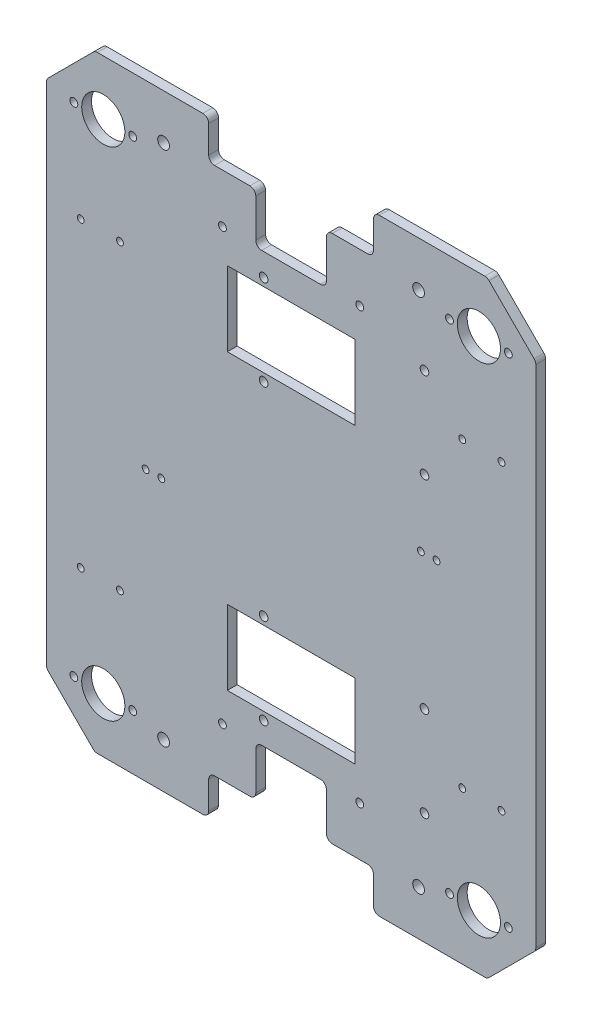
from build123d import *

# Parameters (mm, degrees)
BASE_DEPTH                            = 5
ESQUISSE3_R                           = 2
ESQUISSE3_W                           = 65
ESQUISSE3_H                           = 30
PER_AGE_ROUES_ENCODEUSES_DEPTH        = 6
CONG_1_R                              = 3
PER_AGE_BILLES_PORTEUSES_REACH        = 7
ESQUISSE6_R                           = 2
ESQUISSE6_R_2                         = 11
PER_AGE_PROFIL_S_REACH                = 7
ESQUISSE8_R                           = 3
ESQUISSE15_R                          = 2.2
PER_AGE_BLOC_MOTEUR_DEPTH             = 5
ESQUISSE16_W                          = 65
ESQUISSE16_H                          = 38
ENL_V_MAT_EXTRU_1_DEPTH               = 6
ESQUISSE19_R                          = 1.75
PER_AGE_ACTIONNEUR_MAIN_DE_DIEU_DEPTH = 6


with BuildPart() as part:
    # Esquisse1 → Base (new body)
    with BuildSketch(Plane.XY):
        Polygon((0, 0), (-200, 0), (-224.748737342, 24.748737342), (-224.748737342, 284.748737342), (-200, 309.497474683), (0, 309.497474683), (24.748737342, 284.748737342), (24.748737342, 24.748737342), align=None)
    extrude(amount=BASE_DEPTH)

    # Esquisse3 → Perçage roues encodeuses (cut, through all)
    with BuildSketch(Plane(origin=(0, 0, 0), x_dir=(-1, 0, 0), z_dir=(0, 0, -1))):
        with Locations((65, 45)):
            Circle(ESQUISSE3_R)
        with Locations((135, 45)):
            Circle(ESQUISSE3_R)
        with Locations((135, 264.497474683)):
            Circle(ESQUISSE3_R)
        with Locations((65, 264.497474683)):
            Circle(ESQUISSE3_R)
        Polygon((142, 0), (142, 20), (118, 20), (118, 45.5), (82, 45.5), (82, 20), (58, 20), (58, 0), align=None)
        Polygon((58, 309.497474683), (142, 309.497474683), (142, 289.497474683), (118, 289.497474683), (118, 263.997474683), (82, 263.997474683), (82, 289.497474683), (58, 289.497474683), align=None)
        with Locations((100, 229.497474683)):
            Rectangle(ESQUISSE3_W, ESQUISSE3_H)
        with Locations((100, 80)):
            Rectangle(ESQUISSE3_W, ESQUISSE3_H)
    extrude(amount=-PER_AGE_ROUES_ENCODEUSES_DEPTH, mode=Mode.SUBTRACT)

    # Congé1
    cong_1_edges = [part.edges().sort_by_distance(p)[0] for p in [
        (0, 0, 2.5),
        (-200, 0, 2.5),
        (-224.748737342, 24.748737342, 2.5),
        (-224.748737342, 284.748737342, 2.5),
        (-200, 309.497474683, 2.5),
        (0, 309.497474683, 2.5),
        (24.748737342, 284.748737342, 2.5),
        (24.748737342, 24.748737342, 2.5),
        (-58, 289.497474683, 2.5),
        (-58, 309.497474683, 2.5),
        (-142, 309.497474683, 2.5),
        (-142, 289.497474683, 2.5),
        (-118, 289.497474683, 2.5),
        (-118, 263.997474683, 2.5),
        (-82, 263.997474683, 2.5),
        (-82, 289.497474683, 2.5),
        (-142, 0, 2.5),
        (-58, 0, 2.5),
        (-58, 20, 2.5),
        (-82, 20, 2.5),
        (-82, 45.5, 2.5),
        (-118, 45.5, 2.5),
        (-118, 20, 2.5),
        (-142, 20, 2.5),
    ]]
    fillet(cong_1_edges, radius=CONG_1_R)

    # Esquisse6 → Perçage billes porteuses (cut, up to next)
    with BuildSketch(Plane.XY.offset(5), mode=Mode.PRIVATE) as per_age_billes_porteuses_sk1:
        with Locations((-180.748737342, 28)):
            Circle(ESQUISSE6_R)
    per_age_billes_porteuses_tool1 = extrude(per_age_billes_porteuses_sk1.sketch, amount=-PER_AGE_BILLES_PORTEUSES_REACH, mode=Mode.PRIVATE) & part.part
    add(per_age_billes_porteuses_tool1.solids().sort_by_distance((-180.748737, 28, 5))[0], mode=Mode.SUBTRACT)
    # Esquisse6 → Perçage billes porteuses (cut, up to next)
    with BuildSketch(Plane.XY.offset(5), mode=Mode.PRIVATE) as per_age_billes_porteuses_sk2:
        with Locations((-210.748737342, 28)):
            Circle(ESQUISSE6_R)
    per_age_billes_porteuses_tool2 = extrude(per_age_billes_porteuses_sk2.sketch, amount=-PER_AGE_BILLES_PORTEUSES_REACH, mode=Mode.PRIVATE) & part.part
    add(per_age_billes_porteuses_tool2.solids().sort_by_distance((-210.748737, 28, 5))[0], mode=Mode.SUBTRACT)
    # Esquisse6 → Perçage billes porteuses (cut, up to next)
    with BuildSketch(Plane.XY.offset(5), mode=Mode.PRIVATE) as per_age_billes_porteuses_sk3:
        with Locations((-195.748737342, 28)):
            Circle(ESQUISSE6_R_2)
    per_age_billes_porteuses_tool3 = extrude(per_age_billes_porteuses_sk3.sketch, amount=-PER_AGE_BILLES_PORTEUSES_REACH, mode=Mode.PRIVATE) & part.part
    add(per_age_billes_porteuses_tool3.solids().sort_by_distance((-195.748737, 28, 5))[0], mode=Mode.SUBTRACT)
    # Esquisse6 → Perçage billes porteuses (cut, up to next)
    with BuildSketch(Plane.XY.offset(5), mode=Mode.PRIVATE) as per_age_billes_porteuses_sk4:
        with Locations((-19.251262658, 28)):
            Circle(ESQUISSE6_R)
    per_age_billes_porteuses_tool4 = extrude(per_age_billes_porteuses_sk4.sketch, amount=-PER_AGE_BILLES_PORTEUSES_REACH, mode=Mode.PRIVATE) & part.part
    add(per_age_billes_porteuses_tool4.solids().sort_by_distance((-19.251263, 28, 5))[0], mode=Mode.SUBTRACT)
    # Esquisse6 → Perçage billes porteuses (cut, up to next)
    with BuildSketch(Plane.XY.offset(5), mode=Mode.PRIVATE) as per_age_billes_porteuses_sk5:
        with Locations((10.748737342, 28)):
            Circle(ESQUISSE6_R)
    per_age_billes_porteuses_tool5 = extrude(per_age_billes_porteuses_sk5.sketch, amount=-PER_AGE_BILLES_PORTEUSES_REACH, mode=Mode.PRIVATE) & part.part
    add(per_age_billes_porteuses_tool5.solids().sort_by_distance((10.748737, 28, 5))[0], mode=Mode.SUBTRACT)
    # Esquisse6 → Perçage billes porteuses (cut, up to next)
    with BuildSketch(Plane.XY.offset(5), mode=Mode.PRIVATE) as per_age_billes_porteuses_sk6:
        with Locations((-4.251262658, 28)):
            Circle(ESQUISSE6_R_2)
    per_age_billes_porteuses_tool6 = extrude(per_age_billes_porteuses_sk6.sketch, amount=-PER_AGE_BILLES_PORTEUSES_REACH, mode=Mode.PRIVATE) & part.part
    add(per_age_billes_porteuses_tool6.solids().sort_by_distance((-4.251263, 28, 5))[0], mode=Mode.SUBTRACT)
    # Esquisse6 → Perçage billes porteuses (cut, up to next)
    with BuildSketch(Plane.XY.offset(5), mode=Mode.PRIVATE) as per_age_billes_porteuses_sk7:
        with Locations((-4.251262658, 281.497474683)):
            Circle(ESQUISSE6_R_2)
    per_age_billes_porteuses_tool7 = extrude(per_age_billes_porteuses_sk7.sketch, amount=-PER_AGE_BILLES_PORTEUSES_REACH, mode=Mode.PRIVATE) & part.part
    add(per_age_billes_porteuses_tool7.solids().sort_by_distance((-4.251263, 281.497475, 5))[0], mode=Mode.SUBTRACT)
    # Esquisse6 → Perçage billes porteuses (cut, up to next)
    with BuildSketch(Plane.XY.offset(5), mode=Mode.PRIVATE) as per_age_billes_porteuses_sk8:
        with Locations((10.748737342, 281.497474683)):
            Circle(ESQUISSE6_R)
    per_age_billes_porteuses_tool8 = extrude(per_age_billes_porteuses_sk8.sketch, amount=-PER_AGE_BILLES_PORTEUSES_REACH, mode=Mode.PRIVATE) & part.part
    add(per_age_billes_porteuses_tool8.solids().sort_by_distance((10.748737, 281.497475, 5))[0], mode=Mode.SUBTRACT)
    # Esquisse6 → Perçage billes porteuses (cut, up to next)
    with BuildSketch(Plane.XY.offset(5), mode=Mode.PRIVATE) as per_age_billes_porteuses_sk9:
        with Locations((-19.251262658, 281.497474683)):
            Circle(ESQUISSE6_R)
    per_age_billes_porteuses_tool9 = extrude(per_age_billes_porteuses_sk9.sketch, amount=-PER_AGE_BILLES_PORTEUSES_REACH, mode=Mode.PRIVATE) & part.part
    add(per_age_billes_porteuses_tool9.solids().sort_by_distance((-19.251263, 281.497475, 5))[0], mode=Mode.SUBTRACT)
    # Esquisse6 → Perçage billes porteuses (cut, up to next)
    with BuildSketch(Plane.XY.offset(5), mode=Mode.PRIVATE) as per_age_billes_porteuses_sk10:
        with Locations((-195.748737342, 281.497474683)):
            Circle(ESQUISSE6_R_2)
    per_age_billes_porteuses_tool10 = extrude(per_age_billes_porteuses_sk10.sketch, amount=-PER_AGE_BILLES_PORTEUSES_REACH, mode=Mode.PRIVATE) & part.part
    add(per_age_billes_porteuses_tool10.solids().sort_by_distance((-195.748737, 281.497475, 5))[0], mode=Mode.SUBTRACT)
    # Esquisse6 → Perçage billes porteuses (cut, up to next)
    with BuildSketch(Plane.XY.offset(5), mode=Mode.PRIVATE) as per_age_billes_porteuses_sk11:
        with Locations((-210.748737342, 281.497474683)):
            Circle(ESQUISSE6_R)
    per_age_billes_porteuses_tool11 = extrude(per_age_billes_porteuses_sk11.sketch, amount=-PER_AGE_BILLES_PORTEUSES_REACH, mode=Mode.PRIVATE) & part.part
    add(per_age_billes_porteuses_tool11.solids().sort_by_distance((-210.748737, 281.497475, 5))[0], mode=Mode.SUBTRACT)
    # Esquisse6 → Perçage billes porteuses (cut, up to next)
    with BuildSketch(Plane.XY.offset(5), mode=Mode.PRIVATE) as per_age_billes_porteuses_sk12:
        with Locations((-180.748737342, 281.497474683)):
            Circle(ESQUISSE6_R)
    per_age_billes_porteuses_tool12 = extrude(per_age_billes_porteuses_sk12.sketch, amount=-PER_AGE_BILLES_PORTEUSES_REACH, mode=Mode.PRIVATE) & part.part
    add(per_age_billes_porteuses_tool12.solids().sort_by_distance((-180.748737, 281.497475, 5))[0], mode=Mode.SUBTRACT)

    # Esquisse8 → Perçage profilés (cut, up to next)
    with BuildSketch(Plane.XY.offset(5), mode=Mode.PRIVATE) as per_age_profil_s_sk1:
        with Locations((-165, 23)):
            Circle(ESQUISSE8_R)
    per_age_profil_s_tool1 = extrude(per_age_profil_s_sk1.sketch, amount=-PER_AGE_PROFIL_S_REACH, mode=Mode.PRIVATE) & part.part
    add(per_age_profil_s_tool1.solids().sort_by_distance((-165, 23, 5))[0], mode=Mode.SUBTRACT)
    # Esquisse8 → Perçage profilés (cut, up to next)
    with BuildSketch(Plane.XY.offset(5), mode=Mode.PRIVATE) as per_age_profil_s_sk2:
        with Locations((-165, 286.497474683)):
            Circle(ESQUISSE8_R)
    per_age_profil_s_tool2 = extrude(per_age_profil_s_sk2.sketch, amount=-PER_AGE_PROFIL_S_REACH, mode=Mode.PRIVATE) & part.part
    add(per_age_profil_s_tool2.solids().sort_by_distance((-165, 286.497475, 5))[0], mode=Mode.SUBTRACT)
    # Esquisse8 → Perçage profilés (cut, up to next)
    with BuildSketch(Plane.XY.offset(5), mode=Mode.PRIVATE) as per_age_profil_s_sk3:
        with Locations((-35, 286.497474683)):
            Circle(ESQUISSE8_R)
    per_age_profil_s_tool3 = extrude(per_age_profil_s_sk3.sketch, amount=-PER_AGE_PROFIL_S_REACH, mode=Mode.PRIVATE) & part.part
    add(per_age_profil_s_tool3.solids().sort_by_distance((-35, 286.497475, 5))[0], mode=Mode.SUBTRACT)
    # Esquisse8 → Perçage profilés (cut, up to next)
    with BuildSketch(Plane.XY.offset(5), mode=Mode.PRIVATE) as per_age_profil_s_sk4:
        with Locations((-35, 23)):
            Circle(ESQUISSE8_R)
    per_age_profil_s_tool4 = extrude(per_age_profil_s_sk4.sketch, amount=-PER_AGE_PROFIL_S_REACH, mode=Mode.PRIVATE) & part.part
    add(per_age_profil_s_tool4.solids().sort_by_distance((-35, 23, 5))[0], mode=Mode.SUBTRACT)

    # Esquisse15 → Perçage bloc moteur (cut)
    with BuildSketch(Plane(origin=(0, 0, 0), x_dir=(-1, 0, 0), z_dir=(0, 0, -1))):
        with Locations((114, 103)):
            Circle(ESQUISSE15_R)
        with Locations((32, 103)):
            Circle(ESQUISSE15_R)
        with Locations((114, 57)):
            Circle(ESQUISSE15_R)
        with Locations((32, 57)):
            Circle(ESQUISSE15_R)
        with Locations((32, 252.497474683)):
            Circle(ESQUISSE15_R)
        with Locations((114, 252.497474683)):
            Circle(ESQUISSE15_R)
        with Locations((114, 206.497474683)):
            Circle(ESQUISSE15_R)
        with Locations((32, 206.497474683)):
            Circle(ESQUISSE15_R)
    extrude(amount=-PER_AGE_BLOC_MOTEUR_DEPTH, mode=Mode.SUBTRACT)

    # Esquisse16 → Enlèv. mat.-Extru.1 (cut, through all)
    with BuildSketch(Plane(origin=(0, 0, 0), x_dir=(-1, 0, 0), z_dir=(0, 0, -1))):
        with Locations((100, 80)):
            Rectangle(ESQUISSE16_W, ESQUISSE16_H)
        with Locations((100, 229.497474683)):
            Rectangle(ESQUISSE16_W, ESQUISSE16_H)
    extrude(amount=-ENL_V_MAT_EXTRU_1_DEPTH, mode=Mode.SUBTRACT)

    # Esquisse19 → Perçage actionneur Main_De_Dieu (cut, through all)
    with BuildSketch(Plane(origin=(0, 0, 0), x_dir=(-1, 0, 0), z_dir=(0, 0, -1))):
        with Locations((166.148737342, 137.798737342)):
            Circle(ESQUISSE19_R)
        with Locations((174.148737342, 137.798737342)):
            Circle(ESQUISSE19_R)
        with Locations((-7.248737342, 231.748737342)):
            Circle(ESQUISSE19_R)
        with Locations((12.751262658, 231.748737342)):
            Circle(ESQUISSE19_R)
        with Locations((12.751262658, 77.748737342)):
            Circle(ESQUISSE19_R)
        with Locations((-7.248737342, 77.748737342)):
            Circle(ESQUISSE19_R)
        with Locations((187.248737342, 77.748737342)):
            Circle(ESQUISSE19_R)
        with Locations((207.248737342, 77.748737342)):
            Circle(ESQUISSE19_R)
        with Locations((207.248737342, 231.748737342)):
            Circle(ESQUISSE19_R)
        with Locations((187.248737342, 231.748737342)):
            Circle(ESQUISSE19_R)
        with Locations((25.851262658, 171.698737342)):
            Circle(ESQUISSE19_R)
        with Locations((33.851262658, 171.698737342)):
            Circle(ESQUISSE19_R)
    extrude(amount=-PER_AGE_ACTIONNEUR_MAIN_DE_DIEU_DEPTH, mode=Mode.SUBTRACT)


solid = part.part
